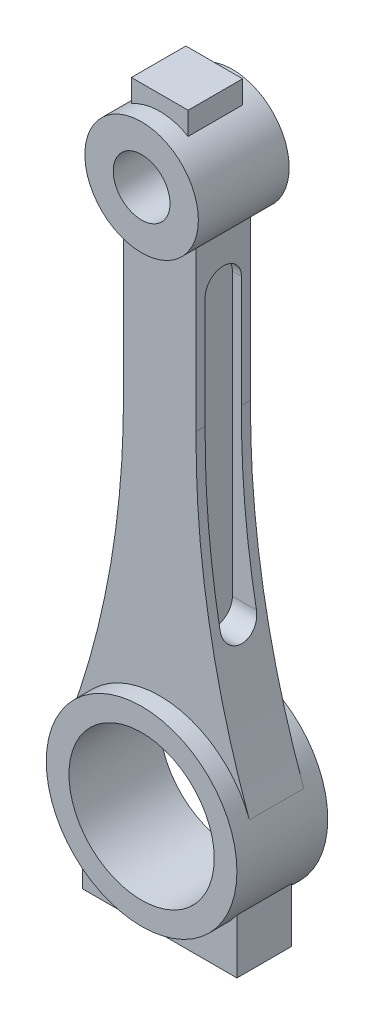
from build123d import *

# Parameters (mm, degrees)
SKETCH1_R             = 317.5
SKETCH1_R_2           = 158.75
BOSS_EXTRUDE1_DEPTH   = 254
SKETCH1_R_3           = 533.4
SKETCH1_R_4           = 406.4
BOSS_EXTRUDE1_2_DEPTH = 254
BOSS_EXTRUDE2_DEPTH   = 152.4
CUT_EXTRUDE1_START    = 152.4
CUT_EXTRUDE1_DEPTH    = 3348.782383063
CUT_EXTRUDE2_START    = -152.4
CUT_EXTRUDE2_DEPTH    = 3348.782383063


with BuildPart() as part:
    # Sketch1 → Boss-Extrude1 (new, symmetric)
    with BuildSketch(Plane.XY):
        with Locations((0, 3048)):
            Circle(SKETCH1_R)
        with Locations((0, 3048)):
            Circle(SKETCH1_R_2, mode=Mode.SUBTRACT)
    extrude(amount=BOSS_EXTRUDE1_DEPTH, both=True)



with BuildPart() as body_2:
    # Sketch1 → Boss-Extrude1 2 (new, symmetric)
    with BuildSketch(Plane.XY):
        Circle(SKETCH1_R_3)
        Circle(SKETCH1_R_4, mode=Mode.SUBTRACT)
    extrude(amount=BOSS_EXTRUDE1_2_DEPTH, both=True)


with BuildPart() as part_1:
    add(part.part)

    add(body_2.part)  # Boss-Extrude2 merges body 2
    # Sketch1_3 → Boss-Extrude2 (add, symmetric)
    with BuildSketch(Plane.XY):
        with BuildLine():
            Line((158.75, 3449.963065702), (-158.75, 3449.963065702))
            Line((-158.75, 3449.963065702), (-158.75, 3322.963065702))
            ThreePointArc((-158.75, 3322.963065702), (0, 3365.5), (158.75, 3322.963065702))
            Line((158.75, 3322.963065702), (158.75, 3449.963065702))
        make_face()
        with BuildLine():
            Line((-203.2, 2804.040966554), (-203.2, 1915.040966554))
            ThreePointArc((-203.2, 1915.040966554), (-274.251603462, 1035.502866401), (-501.112920872, 182.760500479))
            ThreePointArc((-501.112920872, 182.760500479), (0, 533.4), (501.112920872, 182.760500479))
            ThreePointArc((501.112920872, 182.760500479), (274.251603462, 1035.502866401), (203.2, 1915.040966554))
            Line((203.2, 1915.040966554), (203.2, 2804.040966554))
            ThreePointArc((203.2, 2804.040966554), (0, 2730.5), (-203.2, 2804.040966554))
        make_face()
        with BuildLine():
            Line((-431.8, -313.152231351), (-431.8, -617.952231351))
            Line((-431.8, -617.952231351), (431.8, -617.952231351))
            Line((431.8, -617.952231351), (431.8, -313.152231351))
            ThreePointArc((431.8, -313.152231351), (0, -533.4), (-431.8, -313.152231351))
        make_face()
    extrude(amount=BOSS_EXTRUDE2_DEPTH, both=True)

    # Sketch2 → Cut-Extrude1 (cut, through all)
    with BuildSketch(Plane(origin=(0, 0, 0), x_dir=(0, 0, -1), z_dir=(1, 0, 0)).offset(CUT_EXTRUDE1_START)):
        with BuildLine():
            Line((101.6, 2540), (101.6, 965.2))
            ThreePointArc((101.6, 965.2), (0, 863.6), (-101.6, 965.2))
            Line((-101.6, 965.2), (-101.6, 2540))
            ThreePointArc((-101.6, 2540), (0, 2641.6), (101.6, 2540))
        make_face()
    extrude(amount=CUT_EXTRUDE1_DEPTH, mode=Mode.SUBTRACT)

    # Sketch2_2 → Cut-Extrude2 (cut, through all)
    with BuildSketch(Plane(origin=(0, 0, 0), x_dir=(0, 0, -1), z_dir=(1, 0, 0)).offset(CUT_EXTRUDE2_START)):
        with BuildLine():
            Line((101.6, 2540), (101.6, 965.2))
            ThreePointArc((101.6, 965.2), (0, 863.6), (-101.6, 965.2))
            Line((-101.6, 965.2), (-101.6, 2540))
            ThreePointArc((-101.6, 2540), (0, 2641.6), (101.6, 2540))
        make_face()
    extrude(amount=-CUT_EXTRUDE2_DEPTH, mode=Mode.SUBTRACT)


solid = part_1.part
